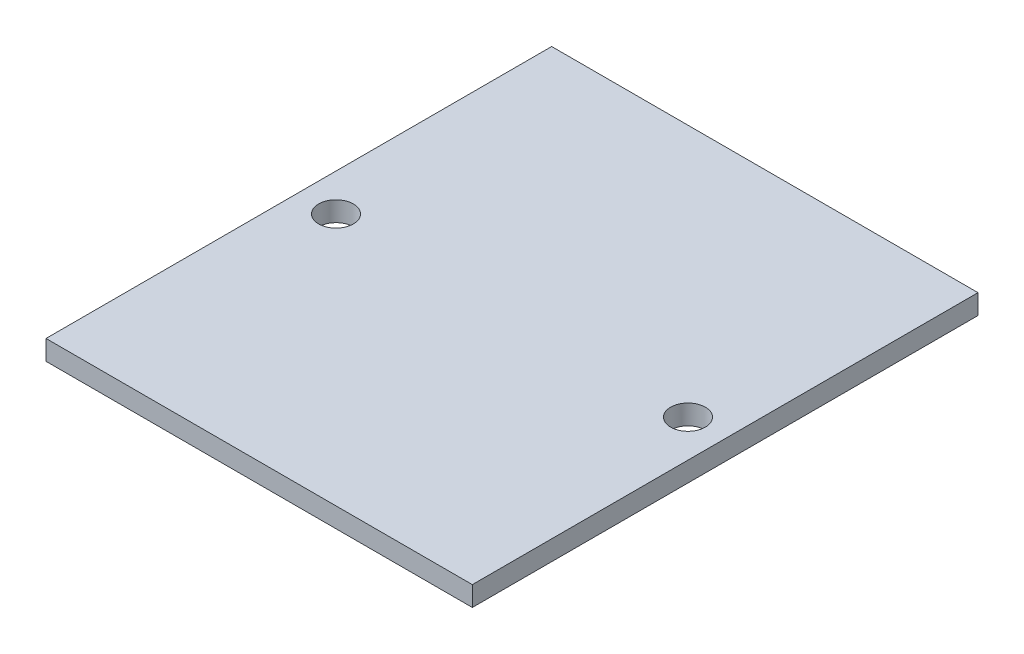
from build123d import *

# Parameters (mm, degrees)
SKETCH1_W           = 43
SKETCH1_H           = 51
BOSS_EXTRUDE1_DEPTH = 2
SKETCH2_R           = 1.75
CUT_EXTRUDE1_DEPTH  = 2


with BuildPart() as part:
    # Sketch1 → Boss-Extrude1 (new body)
    with BuildSketch(Plane(origin=(0, 0, 0), x_dir=(1, 0, 0), z_dir=(0, 1, 0))):
        Rectangle(SKETCH1_W, SKETCH1_H)
    extrude(amount=BOSS_EXTRUDE1_DEPTH)

    # Sketch2 → Cut-Extrude1 (cut)
    with BuildSketch(Plane(origin=(0, 2, 0), x_dir=(1, 0, 0), z_dir=(0, 1, 0))):
        with Locations((-17.75, 0)):
            Circle(SKETCH2_R)
        with Locations((17.75, 0)):
            Circle(SKETCH2_R)
    extrude(amount=-CUT_EXTRUDE1_DEPTH, mode=Mode.SUBTRACT)


solid = part.part
